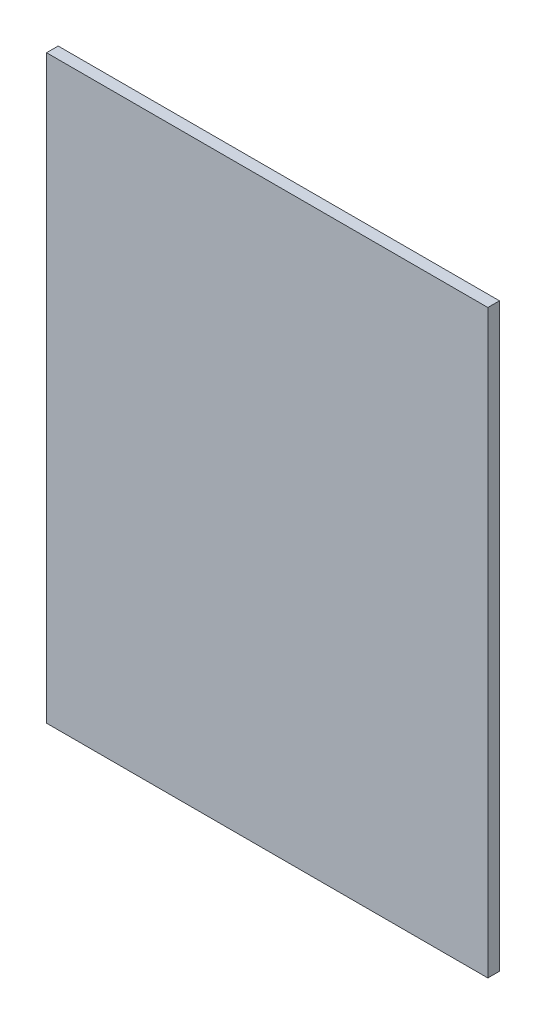
from build123d import *

# Parameters (mm, degrees)
ESQUISSE1_W        = 190
ESQUISSE1_H        = 250
BOSS_EXTRU_2_DEPTH = 5


with BuildPart() as part:
    # Esquisse1 → Boss.-Extru.2 (new body)
    with BuildSketch(Plane.XY):
        with Locations((95, 125)):
            Rectangle(ESQUISSE1_W, ESQUISSE1_H)
    extrude(amount=BOSS_EXTRU_2_DEPTH)


solid = part.part
